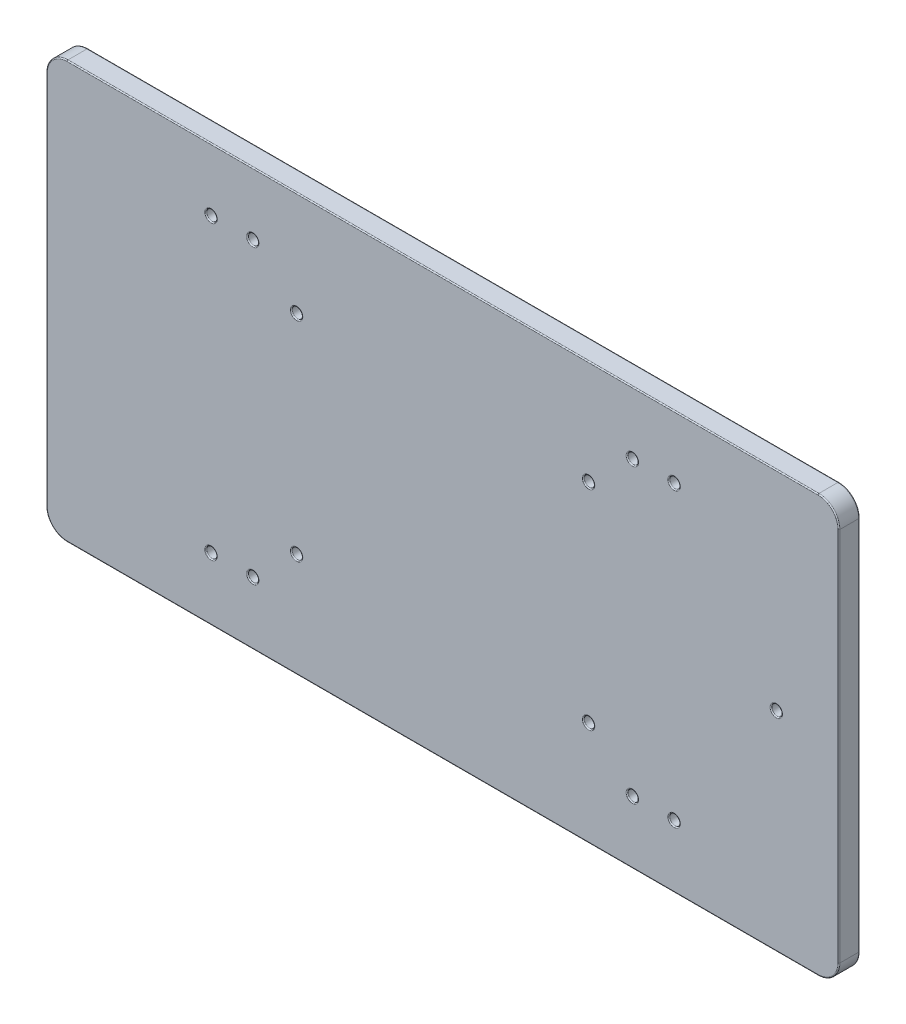
from build123d import *

# Parameters (mm, degrees)
SKETCH2_W           = 190
SKETCH2_H           = 100
SKETCH2_R           = 1.25
BOSS_EXTRUDE1_DEPTH = 5
FILLET1_R           = 5
FILLET2_R           = 0.25


with BuildPart() as part:
    # Sketch2 → Boss-Extrude1 (new body)
    with BuildSketch(Plane.XY):
        Rectangle(SKETCH2_W, SKETCH2_H)
        with Locations((-35, 25)):
            Circle(SKETCH2_R, mode=Mode.SUBTRACT)
        with Locations((35, 25)):
            Circle(SKETCH2_R, mode=Mode.SUBTRACT)
        with Locations((35, -25)):
            Circle(SKETCH2_R, mode=Mode.SUBTRACT)
        with Locations((-35, -25)):
            Circle(SKETCH2_R, mode=Mode.SUBTRACT)
        with Locations((80, 0)):
            Circle(SKETCH2_R, mode=Mode.SUBTRACT)
        with Locations((-55.5, -35)):
            Circle(SKETCH2_R, mode=Mode.SUBTRACT)
        with Locations((-45.5, -35)):
            Circle(SKETCH2_R, mode=Mode.SUBTRACT)
        with Locations((-45.5, 35)):
            Circle(SKETCH2_R, mode=Mode.SUBTRACT)
        with Locations((-55.5, 35)):
            Circle(SKETCH2_R, mode=Mode.SUBTRACT)
        with Locations((45.5, -35)):
            Circle(SKETCH2_R, mode=Mode.SUBTRACT)
        with Locations((55.5, -35)):
            Circle(SKETCH2_R, mode=Mode.SUBTRACT)
        with Locations((55.5, 35)):
            Circle(SKETCH2_R, mode=Mode.SUBTRACT)
        with Locations((45.5, 35)):
            Circle(SKETCH2_R, mode=Mode.SUBTRACT)
    extrude(amount=BOSS_EXTRUDE1_DEPTH)

    # Fillet1
    fillet1_edges = [part.edges().sort_by_distance(p)[0] for p in [
        (95, -50, 2.5),
        (-95, -50, 2.5),
        (-95, 50, 2.5),
        (95, 50, 2.5),
    ]]
    fillet(fillet1_edges, radius=FILLET1_R)

    # Fillet2
    fillet2_edges = [part.edges().sort_by_distance(p)[0] for p in [
        (-36.25, 25, 0),
        (-36.25, 25, 5),
        (33.75, 25, 0),
        (33.75, 25, 5),
        (33.75, -25, 0),
        (33.75, -25, 5),
        (-36.25, -25, 0),
        (-36.25, -25, 5),
        (78.75, 0, 0),
        (78.75, 0, 5),
        (-56.75, -35, 0),
        (-56.75, -35, 5),
        (-46.75, -35, 0),
        (-46.75, -35, 5),
        (-46.75, 35, 0),
        (-46.75, 35, 5),
        (-56.75, 35, 0),
        (-56.75, 35, 5),
        (44.25, -35, 0),
        (44.25, -35, 5),
        (54.25, -35, 0),
        (54.25, -35, 5),
        (54.25, 35, 0),
        (54.25, 35, 5),
        (44.25, 35, 0),
        (44.25, 35, 5),
        (95, 0, 0),
        (95, 0, 5),
        (0, -50, 0),
        (-95, 0, 0),
        (0, 50, 0),
        (-93.535533906, -48.535533906, 0),
        (-93.535533906, 48.535533906, 0),
        (93.535533906, 48.535533906, 0),
        (93.535533906, -48.535533906, 0),
        (0, -50, 5),
        (0, 50, 5),
        (-95, 0, 5),
        (-93.535533906, -48.535533906, 5),
        (-93.535533906, 48.535533906, 5),
        (93.535533906, 48.535533906, 5),
        (93.535533906, -48.535533906, 5),
    ]]
    fillet(fillet2_edges, radius=FILLET2_R)


solid = part.part
